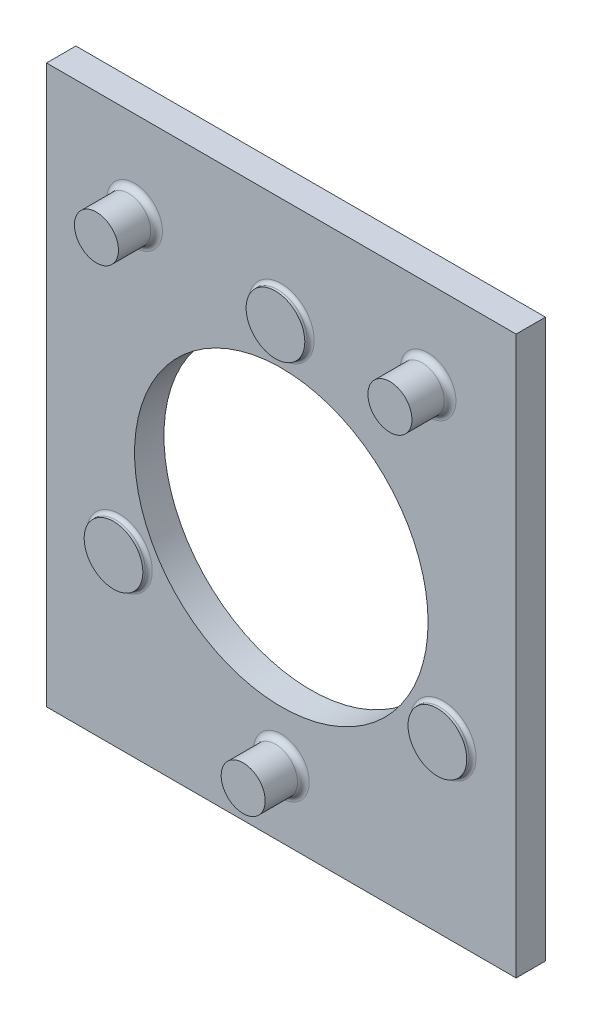
from build123d import *

# Parameters (mm, degrees)
SKETCH1_W           = 203.2
SKETCH1_H           = 241.3
SKETCH1_R           = 63.5
BASE_EXTRUDE_DEPTH  = 12.7
SKETCH3_R           = 12.7
BOSS_EXTRUDE2_DEPTH = 2.54
SKETCH4_R           = 9.525
BOSS_EXTRUDE4_DEPTH = 16.51
SKETCH5_R           = 9.525
BOSS_EXTRUDE5_DEPTH = 16.51
FILLET4_R           = 2.54
FILLET5_R           = 1.524


with BuildPart() as part:
    # Sketch1 → Base-Extrude (new body)
    with BuildSketch(Plane.XY):
        with Locations((101.6, 120.65)):
            Rectangle(SKETCH1_W, SKETCH1_H)
        with Locations((101.6, 114.3)):
            Circle(SKETCH1_R, mode=Mode.SUBTRACT)
    extrude(amount=BASE_EXTRUDE_DEPTH)

    # Sketch3 → Boss-Extrude2 (add)
    with BuildSketch(Plane.XY.offset(12.7)):
        with Locations((31.527468808, 73.843605253)):
            Circle(SKETCH3_R)
        with Locations((101.6, 195.212789493)):
            Circle(SKETCH3_R)
        with Locations((171.672531192, 73.843605253)):
            Circle(SKETCH3_R)
    extrude(amount=BOSS_EXTRUDE2_DEPTH)

    # Sketch4 → Boss-Extrude4 (add)
    with BuildSketch(Plane.XY.offset(12.7)):
        with Locations((38.1, 203.2)):
            Circle(SKETCH4_R)
        with Locations((165.1, 203.2)):
            Circle(SKETCH4_R)
    extrude(amount=BOSS_EXTRUDE4_DEPTH)

    # Sketch5 → Boss-Extrude5 (add)
    with BuildSketch(Plane.XY.offset(12.7)):
        with Locations((101.6, 28.575)):
            Circle(SKETCH5_R)
    extrude(amount=BOSS_EXTRUDE5_DEPTH)

    # Fillet4
    fillet4_edges = [part.edges().sort_by_distance(p)[0] for p in [
        (28.575, 203.2, 12.7),
        (155.575, 203.2, 12.7),
        (92.075, 28.575, 12.7),
    ]]
    fillet(fillet4_edges, radius=FILLET4_R)

    # Fillet5
    fillet5_edges = [part.edges().sort_by_distance(p)[0] for p in [
        (18.827468808, 73.843605253, 12.7),
        (88.9, 195.212789493, 12.7),
        (158.972531192, 73.843605253, 12.7),
    ]]
    fillet(fillet5_edges, radius=FILLET5_R)


solid = part.part
